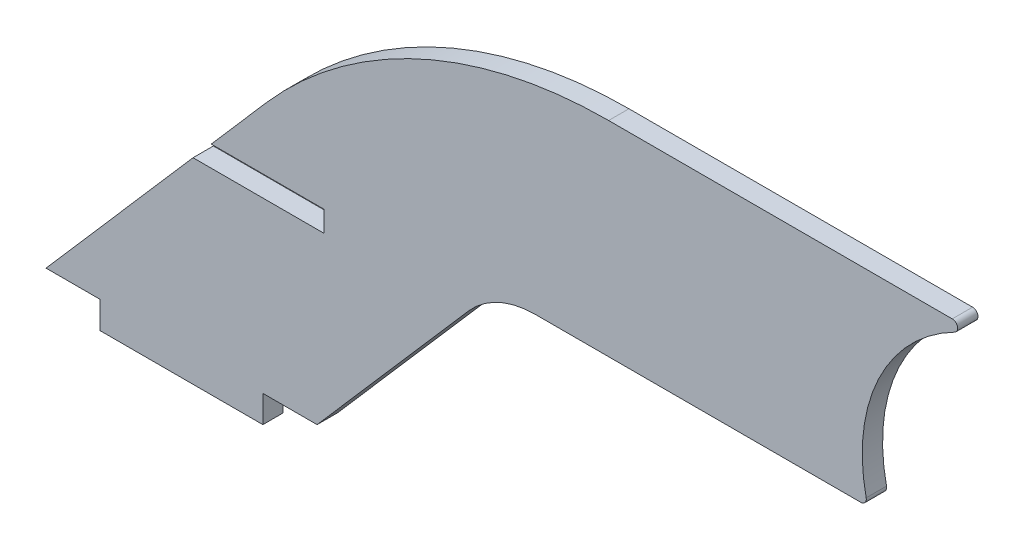
from build123d import *

# Parameters (mm, degrees)
BOSS_EXTRUDE1_DEPTH = 3
SKETCH2_W           = 31.541335057
SKETCH2_H           = 3.08
CUT_EXTRUDE1_DEPTH  = 3


with BuildPart() as part:
    # Sketch1 → Boss-Extrude1 (new body)
    with BuildSketch(Plane.XY):
        with BuildLine():
            Line((12.452839565, 41.33272136), (-20, 4))
            Line((-20, 4), (-12, 4))
            Line((-12, 4), (-12, 0))
            Line((-12, 0), (12, 0))
            Line((12, 0), (12, 4))
            Line((12, 4), (20, 4))
            Line((20, 4), (42.354172484, 29.715533795))
            ThreePointArc((42.354172484, 29.715533795), (46.774384872, 33.016262939), (52.165397026, 34.186766418))
            Line((52.165397026, 34.186766418), (100.240955705, 34.186766418))
            ThreePointArc((100.240955705, 34.186766418), (100.86429233, 34.485317067), (101.02238507, 35.158137789))
            ThreePointArc((101.02238507, 35.158137789), (102.836349044, 51.235945442), (114.085991202, 62.864871253))
            ThreePointArc((114.085991202, 62.864871253), (114.498680148, 63.764494769), (113.721018225, 64.376766418))
            Line((113.721018225, 64.376766418), (63.01838144, 64.376766418))
            ThreePointArc((63.01838144, 64.376766418), (35.233934182, 58.344171567), (12.452839565, 41.33272136))
        make_face()
    extrude(amount=BOSS_EXTRUDE1_DEPTH)

    # Sketch2 → Cut-Extrude1 (cut)
    with BuildSketch(Plane.XY.offset(3)):
        with Locations((5.229332471, 30.5)):
            Rectangle(SKETCH2_W, SKETCH2_H)
    extrude(amount=-CUT_EXTRUDE1_DEPTH, mode=Mode.SUBTRACT)


solid = part.part
